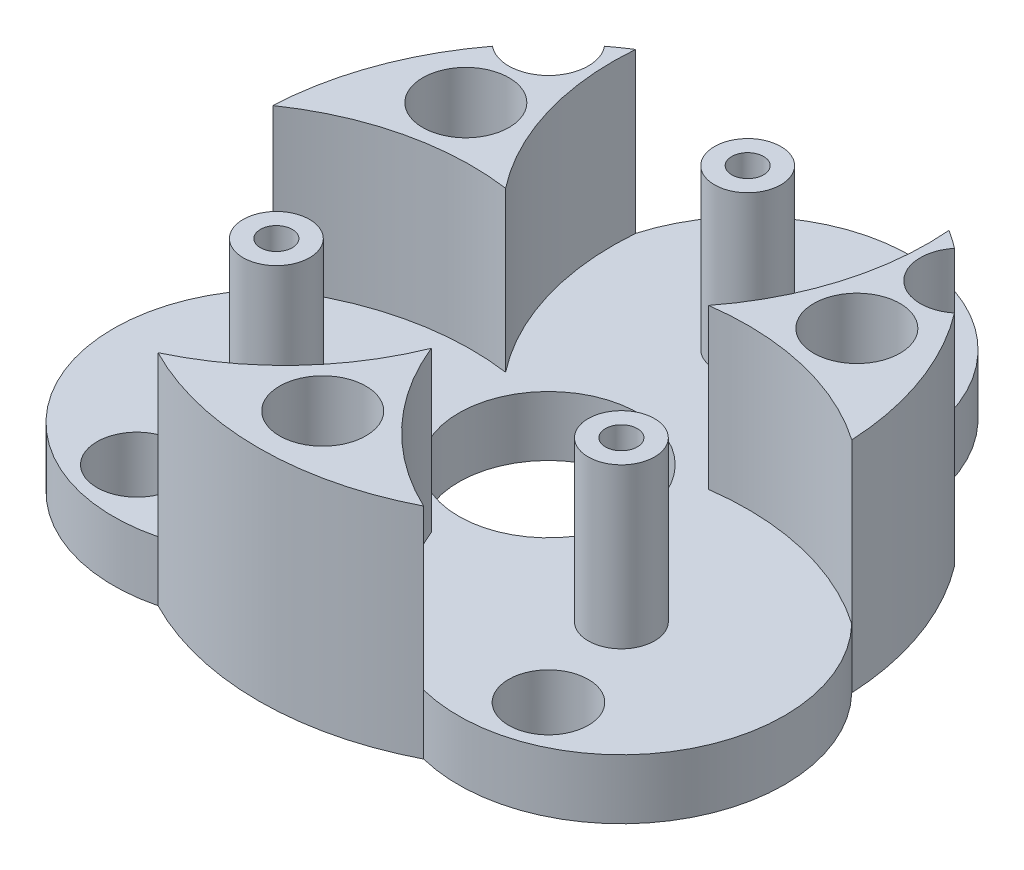
from build123d import *

# Parameters (mm, degrees)
CROQUIS1_R                                           = 21.825
SALIENTE_EXTRUIR1_DEPTH                              = 4.5
CROQUIS2_R                                           = 2.5
SALIENTE_EXTRUIR2_DEPTH                              = 12
TALADRO_DE_MARGEN_PARA_M121_D                        = 13.5
SALIENTE_EXTRUIR3_DEPTH                              = 12
CROQUIS8_R                                           = 1.7
CORTAR_EXTRUIR1_DEPTH                                = 16.5
MATRIZC1_COUNT                                       = 3
TALADRO_DE_MARGEN_PARA_M21_D                         = 2.4
SALIENTE_EXTRUIR5_DEPTH                              = 4.5
MATRIZC2_COUNT                                       = 3
CROQUIS12_R                                          = 2.875
CORTAR_EXTRUIR2_DEPTH                                = 2.2
CROQUIS13_R                                          = 3
CORTAR_EXTRUIR3_DEPTH                                = 16.5
REFRENTADO_PARA_TORNILLO_CON_CABEZA_PLAN_D           = 3.4
REFRENTADO_PARA_TORNILLO_CON_CABEZA_PLAN_CBORE_D     = 6.5
REFRENTADO_PARA_TORNILLO_CON_CABEZA_PLAN_CBORE_DEPTH = 10


with BuildPart() as part:
    # Croquis1 → Saliente-Extruir1 (new body)
    with BuildSketch(Plane(origin=(0, 0, 0), x_dir=(1, 0, 0), z_dir=(0, 1, 0))):
        Circle(CROQUIS1_R)
    extrude(amount=SALIENTE_EXTRUIR1_DEPTH)

    # Croquis2 → Saliente-Extruir2 (add)
    with BuildSketch(Plane(origin=(0, 4.5, 0), x_dir=(1, 0, 0), z_dir=(0, 1, 0))):
        with Locations((0, 15)):
            Circle(CROQUIS2_R)
        with Locations((12.990381057, -7.5)):
            Circle(CROQUIS2_R)
        with Locations((-12.990381057, -7.5)):
            Circle(CROQUIS2_R)
    extrude(amount=SALIENTE_EXTRUIR2_DEPTH)

    # Taladro de margen para M121 (through all)
    with Locations(Plane(origin=(0, 4.5, 0), x_dir=(1, 0, 0), z_dir=(0, 1, 0))):
        with Locations((0, 0)):
            Hole(TALADRO_DE_MARGEN_PARA_M121_D / 2)

    # Croquis5 → Saliente-Extruir3 (add)
    with BuildSketch(Plane(origin=(0, 4.5, 0), x_dir=(1, 0, 0), z_dir=(0, 1, 0))):
        with BuildLine():
            ThreePointArc((-7.642674188, 4.4125), (-11.035446071, 10.994501306), (-11.800237164, 18.359875487))
            ThreePointArc((-11.800237164, 18.359875487), (-18.901004438, 10.9125), (-21.800237164, 1.039367411))
            ThreePointArc((-21.800237164, 1.039367411), (-15.039240468, 4.059725986), (-7.642674188, 4.4125))
        make_face()
    saliente_extruir3 = extrude(amount=SALIENTE_EXTRUIR3_DEPTH)

    # Croquis8 → Cortar-Extruir1 (cut)
    with BuildSketch(Plane(origin=(0, 16.5, 0), x_dir=(1, 0, 0), z_dir=(0, 1, 0))):
        with Locations((-14.722431864, 8.5)):
            Circle(CROQUIS8_R)
    cortar_extruir1 = extrude(amount=-CORTAR_EXTRUIR1_DEPTH, mode=Mode.SUBTRACT)

    # MatrizC1: Saliente-Extruir3, Cortar-Extruir1 ×3 about axis
    matrizc1_axis = Axis((0, 0, 0), (0, 1, 0))
    for i in range(1, MATRIZC1_COUNT):
        add(saliente_extruir3.rotate(matrizc1_axis, i * 360 / MATRIZC1_COUNT))
        add(cortar_extruir1.rotate(matrizc1_axis, i * 360 / MATRIZC1_COUNT), mode=Mode.SUBTRACT)

    # Taladro de margen para M21 (through all)
    with Locations(Plane(origin=(0, 16.5, 0), x_dir=(1, 0, 0), z_dir=(0, 1, 0))):
        with Locations((12.990381057, -7.5), (-12.990381057, -7.5), (0, 15)):
            Hole(TALADRO_DE_MARGEN_PARA_M21_D / 2)

    # Croquis11 → Saliente-Extruir5 (add)
    with BuildSketch(Plane.XZ):
        with BuildLine():
            ThreePointArc((-10, 19.399242898), (-18.901004438, 10.9125), (-21.800237164, -1.039367411))
            ThreePointArc((-21.800237164, -1.039367411), (-23.615858472, 13.634622246), (-10, 19.399242898))
        make_face()
    saliente_extruir5 = extrude(amount=-SALIENTE_EXTRUIR5_DEPTH)

    # MatrizC2: Saliente-Extruir5 ×3 about axis
    matrizc2_axis = Axis((0, 0, 0), (0, 1, 0))
    for i in range(1, MATRIZC2_COUNT):
        add(saliente_extruir5.rotate(matrizc2_axis, i * 360 / MATRIZC2_COUNT))

    # Croquis12 → Cortar-Extruir2 (cut)
    with BuildSketch(Plane.XZ):
        with Locations((-12.990381057, 7.5)):
            Circle(CROQUIS12_R)
        with Locations((12.990381057, 7.5)):
            Circle(CROQUIS12_R)
        with Locations((0, -15)):
            Circle(CROQUIS12_R)
    extrude(amount=-CORTAR_EXTRUIR2_DEPTH, mode=Mode.SUBTRACT)

    # Croquis13 → Cortar-Extruir3 (cut)
    with BuildSketch(Plane.XZ):
        with Locations((15.5, -15.5)):
            Circle(CROQUIS13_R)
        with Locations((-15.5, -15.5)):
            Circle(CROQUIS13_R)
        with Locations((-15.5, 15.5)):
            Circle(CROQUIS13_R)
        with Locations((15.5, 15.5)):
            Circle(CROQUIS13_R)
    extrude(amount=-CORTAR_EXTRUIR3_DEPTH, mode=Mode.SUBTRACT)

    # Refrentado para tornillo con cabeza plana de M31 (through all)
    with Locations(Plane(origin=(0, 16.5, 0), x_dir=(1, 0, 0), z_dir=(0, 1, 0))):
        with Locations((-14.722431864, 8.5), (0, -17), (14.722431864, 8.5)):
            CounterBoreHole(REFRENTADO_PARA_TORNILLO_CON_CABEZA_PLAN_D / 2, REFRENTADO_PARA_TORNILLO_CON_CABEZA_PLAN_CBORE_D / 2, REFRENTADO_PARA_TORNILLO_CON_CABEZA_PLAN_CBORE_DEPTH)


solid = part.part
